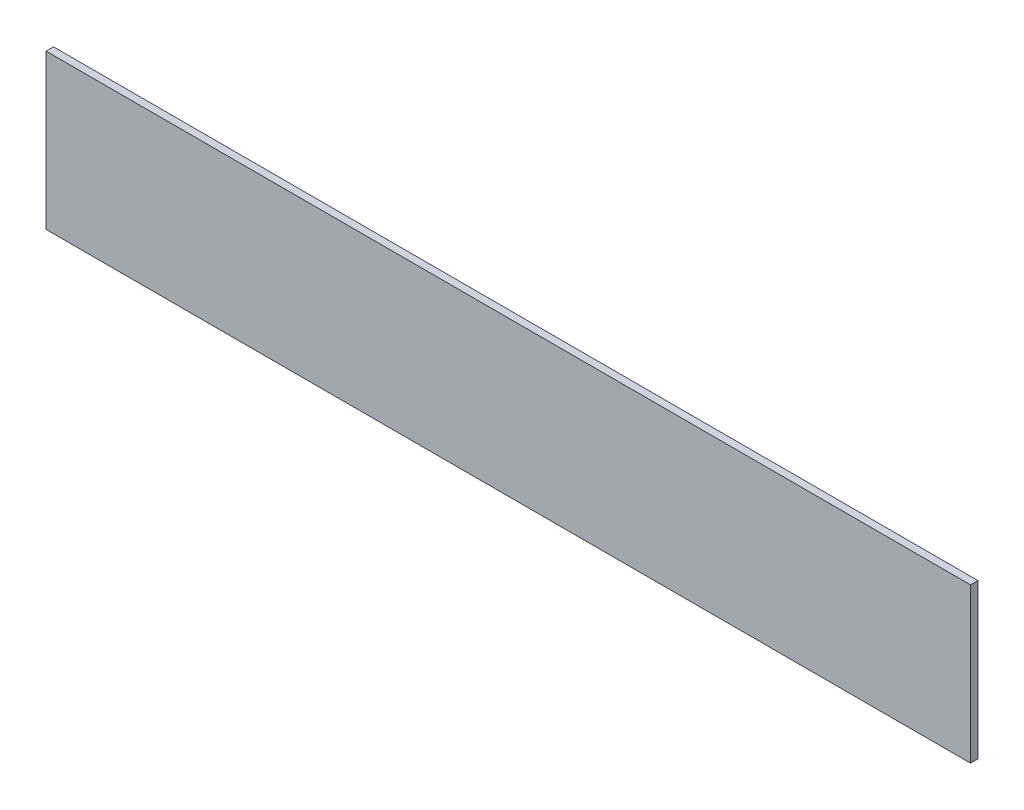
from build123d import *

# Parameters (mm, degrees)
SKETCH1_W           = 380.1872
SKETCH1_H           = 63.5
BOSS_EXTRUDE1_DEPTH = 3.048


with BuildPart() as part:
    # Sketch1 → Boss-Extrude1 (new body)
    with BuildSketch(Plane.XY):
        with Locations((190.0936, 31.75)):
            Rectangle(SKETCH1_W, SKETCH1_H)
    extrude(amount=BOSS_EXTRUDE1_DEPTH)


solid = part.part
